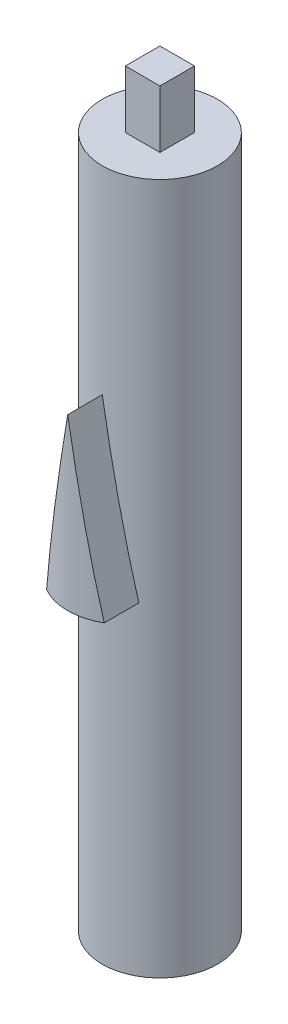
from build123d import *

# Parameters (mm, degrees)
SKETCH1_R                  = 5
BOSS_EXTRUDE1_DEPTH        = 60
SKETCH2_W                  = 5
SKETCH2_H                  = 3
CUT_EXTRUDE1_DEPTH         = 6
BOSS_EXTRUDE2_REACH        = 65.415
BOSS_EXTRUDE2_START_RADIUS = 5
BOSS_EXTRUDE2_END_RADIUS   = 5
SKETCH4_W                  = 3
SKETCH4_H                  = 3
BOSS_EXTRUDE3_DEPTH        = 5


with BuildPart() as part:
    # Sketch1 → Boss-Extrude1 (new body)
    with BuildSketch(Plane(origin=(0, 0, 0), x_dir=(1, 0, 0), z_dir=(0, 1, 0))):
        Circle(SKETCH1_R)
    extrude(amount=BOSS_EXTRUDE1_DEPTH)

    # Sketch2 → Cut-Extrude1 (cut)
    with BuildSketch(Plane.XZ):
        Rectangle(SKETCH2_W, SKETCH2_H)
    extrude(amount=-CUT_EXTRUDE1_DEPTH, mode=Mode.SUBTRACT)

    # Boss-Extrude2: from a cylinder face, 65.415 long prism both ways, kept between that surface and its translate by the depth
    boss_extrude2_start = Plane(origin=(0, 32.976643, 0), z_dir=(0, -1, 0)) * Cylinder(BOSS_EXTRUDE2_START_RADIUS, 141.83, mode=Mode.PRIVATE)
    boss_extrude2_end = Plane(origin=(0, 32.976643, 3), z_dir=(0, -1, 0)) * Cylinder(BOSS_EXTRUDE2_END_RADIUS, 141.83, mode=Mode.PRIVATE)
    # Sketch3 → Boss-Extrude2 (add, from a surface)
    with BuildSketch(Plane.XY, mode=Mode.PRIVATE) as boss_extrude2_sk1:
        Polygon((0, 42.798210841), (-2.5, 28.065858852), (2.5, 28.065858852), align=None)
    boss_extrude2_tool1 = extrude(boss_extrude2_sk1.sketch, amount=BOSS_EXTRUDE2_REACH, both=True, mode=Mode.PRIVATE)
    add(((boss_extrude2_tool1 - boss_extrude2_start) & boss_extrude2_end).solids().sort_by_distance((0, 60, 5))[0])

    # Sketch4 → Boss-Extrude3 (add)
    with BuildSketch(Plane(origin=(0, 60, 0), x_dir=(1, 0, 0), z_dir=(0, 1, 0))):
        Rectangle(SKETCH4_W, SKETCH4_H)
    extrude(amount=BOSS_EXTRUDE3_DEPTH)


solid = part.part
